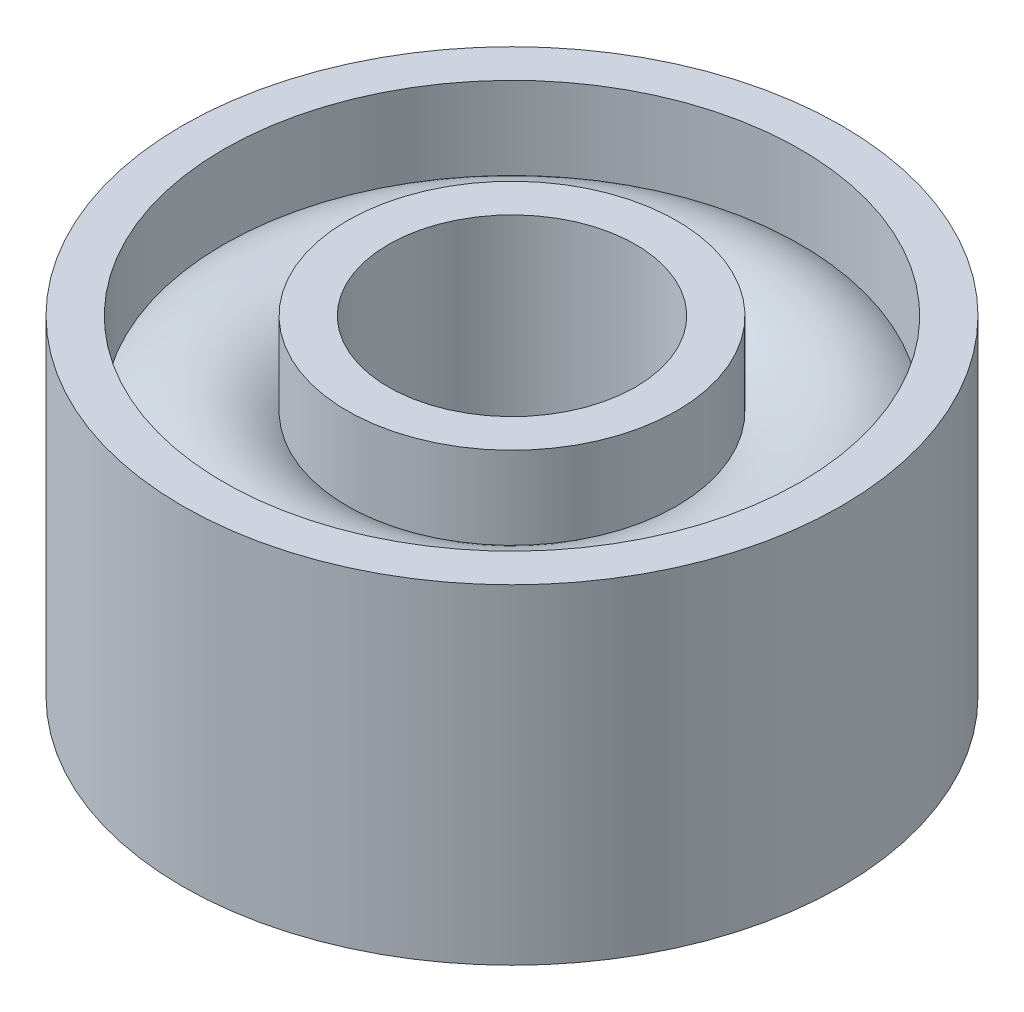
from build123d import *


with BuildPart() as part:
    # Sketch1 → Revolve1 (revolve)
    with BuildSketch(Plane.XY):
        with BuildLine():
            Line((1.5, 2), (1.5, -2))
            Line((1.5, -2), (2, -2))
            Line((2, -2), (2, -1))
            ThreePointArc((2, -1), (2.75, -1.25), (3.5, -1))
            Line((3.5, -1), (3.5, -2))
            Line((3.5, -2), (4, -2))
            Line((4, -2), (4, 2))
            Line((4, 2), (3.5, 2))
            Line((3.5, 2), (3.5, 1))
            ThreePointArc((3.5, 1), (2.75, 1.25), (2, 1))
            Line((2, 1), (2, 2))
            Line((2, 2), (1.5, 2))
        make_face()
    revolve(axis=Axis((0, 1.338212484, 0), (0, -1, 0)))


solid = part.part
